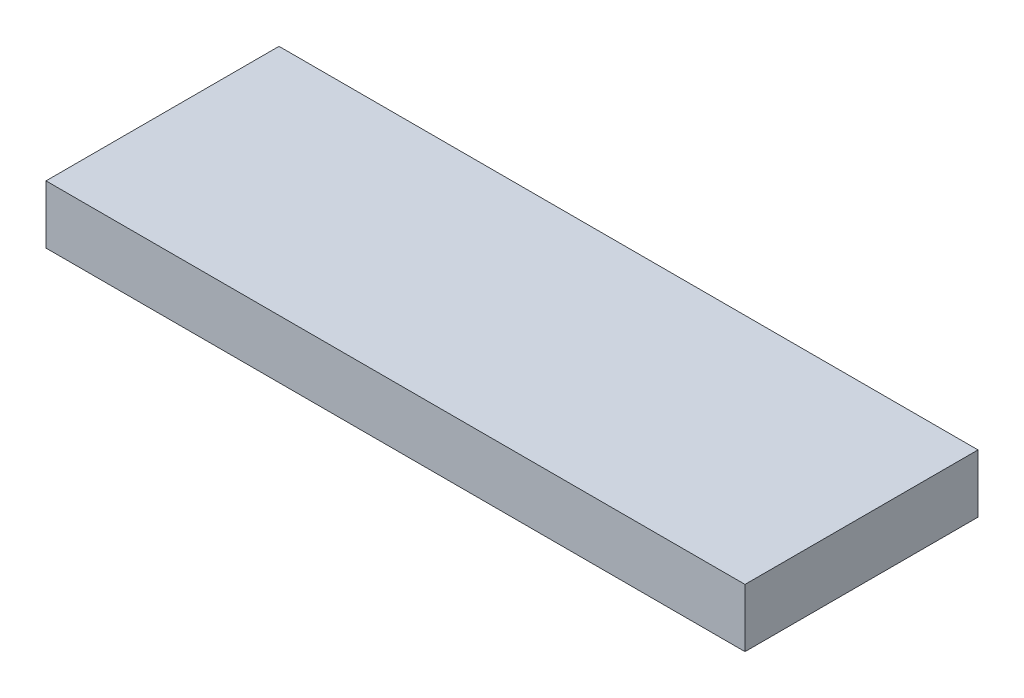
from build123d import *

# Parameters (mm, degrees)
SKETCH1_W           = 120
SKETCH1_H           = 40
BOSS_EXTRUDE1_DEPTH = 10


with BuildPart() as part:
    # Sketch1 → Boss-Extrude1 (new body)
    with BuildSketch(Plane(origin=(0, 0, 0), x_dir=(1, 0, 0), z_dir=(0, 1, 0))):
        Rectangle(SKETCH1_W, SKETCH1_H)
    extrude(amount=BOSS_EXTRUDE1_DEPTH)


solid = part.part
